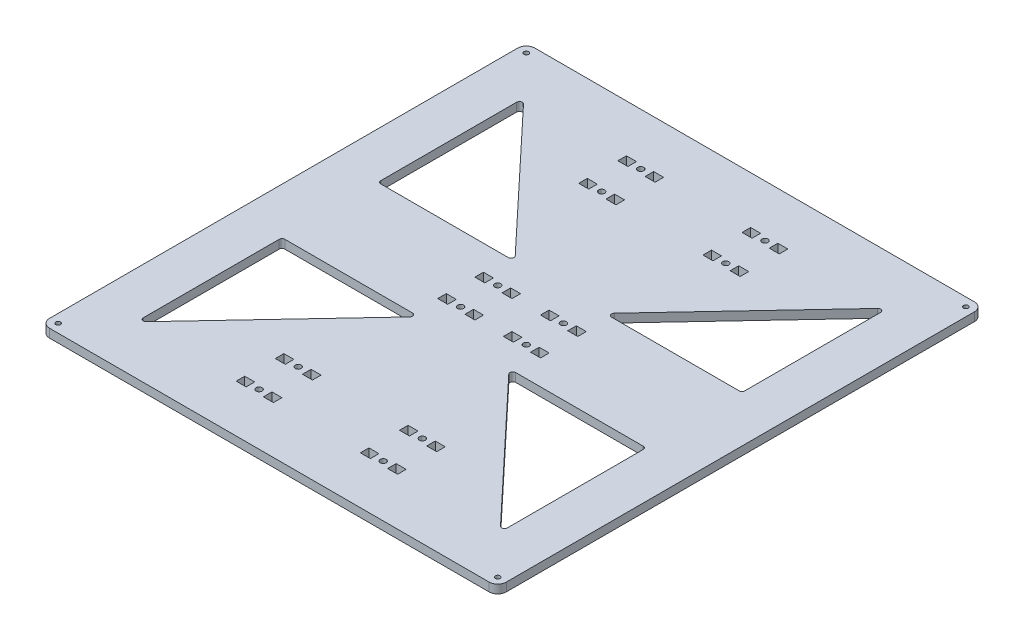
from build123d import *

# Parameters (mm, degrees)
SKETCH_1_R            = 1.65
EXTRUDE_1_DEPTH       = 6
SKETCH_3_R            = 2.1
SKETCH_3_W            = 7
SKETCH_3_H            = 6
CUT_EXTRUDE_1_DEPTH   = 7
SKETCH_31_R           = 2.1
SKETCH_31_W           = 7
SKETCH_31_H           = 6
CUT_EXTRUDE_11_DEPTH  = 7
SKETCH_32_R           = 2.1
SKETCH_32_W           = 7
SKETCH_32_H           = 6
CUT_EXTRUDE_12_DEPTH  = 7
SKETCH_33_R           = 2.1
SKETCH_33_W           = 7
SKETCH_33_H           = 6
CUT_EXTRUDE_13_DEPTH  = 7
SKETCH_34_R           = 2.1
SKETCH_34_W           = 7
SKETCH_34_H           = 6
CUT_EXTRUDE_14_DEPTH  = 7
SKETCH_35_R           = 2.1
SKETCH_35_W           = 7
SKETCH_35_H           = 6
CUT_EXTRUDE_15_DEPTH  = 7
SKETCH_37_R           = 2.1
SKETCH_37_W           = 7
SKETCH_37_H           = 6
CUT_EXTRUDE_17_DEPTH  = 7
SKETCH_38_R           = 2.1
SKETCH_38_W           = 7
SKETCH_38_H           = 6
CUT_EXTRUDE_18_DEPTH  = 7
SKETCH_39_R           = 2.1
SKETCH_39_W           = 7
SKETCH_39_H           = 6
CUT_EXTRUDE_19_DEPTH  = 7
SKETCH_310_R          = 2.1
SKETCH_310_W          = 7
SKETCH_310_H          = 6
CUT_EXTRUDE_110_DEPTH = 7
SKETCH_311_R          = 2.1
SKETCH_311_W          = 7
SKETCH_311_H          = 6
CUT_EXTRUDE_111_DEPTH = 7
SKETCH_312_R          = 2.1
SKETCH_312_W          = 7
SKETCH_312_H          = 6
CUT_EXTRUDE_112_DEPTH = 7
CUT_EXTRUDE_113_DEPTH = 7


with BuildPart() as part:
    # Эскиз1 → Бобышка-Вытянуть1 (new body)
    with BuildSketch(Plane(origin=(0, 0, 0), x_dir=(1, 0, 0), z_dir=(0, 1, 0))):
        with BuildLine():
            Line((-154, -156), (154, -156))
            ThreePointArc((154, -156), (158.242640687, -154.242640687), (160, -150))
            Line((160, -150), (160, 178))
            ThreePointArc((160, 178), (158.242640687, 182.242640687), (154, 184))
            Line((154, 184), (-154, 184))
            ThreePointArc((-154, 184), (-158.242640687, 182.242640687), (-160, 178))
            Line((-160, 178), (-160, -150))
            ThreePointArc((-160, -150), (-158.242640687, -154.242640687), (-154, -156))
        make_face()
        with Locations((-154, 178)):
            Circle(SKETCH_1_R, mode=Mode.SUBTRACT)
        with Locations((154, 178)):
            Circle(SKETCH_1_R, mode=Mode.SUBTRACT)
        with Locations((-154, -150)):
            Circle(SKETCH_1_R, mode=Mode.SUBTRACT)
        with Locations((154, -150)):
            Circle(SKETCH_1_R, mode=Mode.SUBTRACT)
    extrude(amount=EXTRUDE_1_DEPTH)

    # Эскиз3 → Вырез-Вытянуть1 (cut, through all)
    with BuildSketch(Plane(origin=(-23, 6, 20), x_dir=(1, 0, 0), z_dir=(0, 1, 0))):
        with Locations((0, 47)):
            Circle(SKETCH_3_R)
        with Locations((9.531849908, 47)):
            Rectangle(SKETCH_3_W, SKETCH_3_H)
        with Locations((-9.531849908, 47)):
            Rectangle(SKETCH_3_W, SKETCH_3_H)
    extrude(amount=-CUT_EXTRUDE_1_DEPTH, mode=Mode.SUBTRACT)

    # Эскиз31 → Вырез-Вытянуть11 (cut, through all)
    with BuildSketch(Plane(origin=(-23, 6, -48), x_dir=(-1, 0, 0), z_dir=(0, 1, 0))):
        with Locations((0, 47)):
            Circle(SKETCH_31_R)
        with Locations((9.531849908, 47)):
            Rectangle(SKETCH_31_W, SKETCH_31_H)
        with Locations((-9.531849908, 47)):
            Rectangle(SKETCH_31_W, SKETCH_31_H)
    extrude(amount=-CUT_EXTRUDE_11_DEPTH, mode=Mode.SUBTRACT)

    # Эскиз32 → Вырез-Вытянуть12 (cut, through all)
    with BuildSketch(Plane(origin=(23, 6, 20), x_dir=(1, 0, 0), z_dir=(0, 1, 0))):
        with Locations((0, 47)):
            Circle(SKETCH_32_R)
        with Locations((9.531849908, 47)):
            Rectangle(SKETCH_32_W, SKETCH_32_H)
        with Locations((-9.531849908, 47)):
            Rectangle(SKETCH_32_W, SKETCH_32_H)
    extrude(amount=-CUT_EXTRUDE_12_DEPTH, mode=Mode.SUBTRACT)

    # Эскиз33 → Вырез-Вытянуть13 (cut, through all)
    with BuildSketch(Plane(origin=(23, 6, -48), x_dir=(-1, 0, 0), z_dir=(0, 1, 0))):
        with Locations((0, 47)):
            Circle(SKETCH_33_R)
        with Locations((9.531849908, 47)):
            Rectangle(SKETCH_33_W, SKETCH_33_H)
        with Locations((-9.531849908, 47)):
            Rectangle(SKETCH_33_W, SKETCH_33_H)
    extrude(amount=-CUT_EXTRUDE_13_DEPTH, mode=Mode.SUBTRACT)

    # Эскиз34 → Вырез-Вытянуть14 (cut, through all)
    with BuildSketch(Plane(origin=(43.5, 6, 72.7), x_dir=(-1, 0, 0), z_dir=(0, 1, 0))):
        with Locations((0, 47)):
            Circle(SKETCH_34_R)
        with Locations((9.531849908, 47)):
            Rectangle(SKETCH_34_W, SKETCH_34_H)
        with Locations((-9.531849908, 47)):
            Rectangle(SKETCH_34_W, SKETCH_34_H)
    extrude(amount=-CUT_EXTRUDE_14_DEPTH, mode=Mode.SUBTRACT)

    # Эскиз35 → Вырез-Вытянуть15 (cut, through all)
    with BuildSketch(Plane(origin=(43.5, 6, 139.3), x_dir=(1, 0, 0), z_dir=(0, 1, 0))):
        with Locations((0, 47)):
            Circle(SKETCH_35_R)
        with Locations((9.531849908, 47)):
            Rectangle(SKETCH_35_W, SKETCH_35_H)
        with Locations((-9.531849908, 47)):
            Rectangle(SKETCH_35_W, SKETCH_35_H)
    extrude(amount=-CUT_EXTRUDE_15_DEPTH, mode=Mode.SUBTRACT)

    # Эскиз37 → Вырез-Вытянуть17 (cut, through all)
    with BuildSketch(Plane(origin=(-43.5, 6, 139.3), x_dir=(1, 0, 0), z_dir=(0, 1, 0))):
        with Locations((0, 47)):
            Circle(SKETCH_37_R)
        with Locations((9.531849908, 47)):
            Rectangle(SKETCH_37_W, SKETCH_37_H)
        with Locations((-9.531849908, 47)):
            Rectangle(SKETCH_37_W, SKETCH_37_H)
    extrude(amount=-CUT_EXTRUDE_17_DEPTH, mode=Mode.SUBTRACT)

    # Эскиз38 → Вырез-Вытянуть18 (cut, through all)
    with BuildSketch(Plane(origin=(-43.5, 6, 72.7), x_dir=(-1, 0, 0), z_dir=(0, 1, 0))):
        with Locations((0, 47)):
            Circle(SKETCH_38_R)
        with Locations((9.531849908, 47)):
            Rectangle(SKETCH_38_W, SKETCH_38_H)
        with Locations((-9.531849908, 47)):
            Rectangle(SKETCH_38_W, SKETCH_38_H)
    extrude(amount=-CUT_EXTRUDE_18_DEPTH, mode=Mode.SUBTRACT)

    # Эскиз39 → Вырез-Вытянуть19 (cut, through all)
    with BuildSketch(Plane(origin=(-43.5, 6, -100.7), x_dir=(1, 0, 0), z_dir=(0, 1, 0))):
        with Locations((0, 47)):
            Circle(SKETCH_39_R)
        with Locations((9.531849908, 47)):
            Rectangle(SKETCH_39_W, SKETCH_39_H)
        with Locations((-9.531849908, 47)):
            Rectangle(SKETCH_39_W, SKETCH_39_H)
    extrude(amount=-CUT_EXTRUDE_19_DEPTH, mode=Mode.SUBTRACT)

    # Эскиз310 → Вырез-Вытянуть110 (cut, through all)
    with BuildSketch(Plane(origin=(43.5, 6, -100.7), x_dir=(1, 0, 0), z_dir=(0, 1, 0))):
        with Locations((0, 47)):
            Circle(SKETCH_310_R)
        with Locations((9.531849908, 47)):
            Rectangle(SKETCH_310_W, SKETCH_310_H)
        with Locations((-9.531849908, 47)):
            Rectangle(SKETCH_310_W, SKETCH_310_H)
    extrude(amount=-CUT_EXTRUDE_110_DEPTH, mode=Mode.SUBTRACT)

    # Эскиз311 → Вырез-Вытянуть111 (cut, through all)
    with BuildSketch(Plane(origin=(-43.5, 6, -167.3), x_dir=(-1, 0, 0), z_dir=(0, 1, 0))):
        with Locations((0, 47)):
            Circle(SKETCH_311_R)
        with Locations((9.531849908, 47)):
            Rectangle(SKETCH_311_W, SKETCH_311_H)
        with Locations((-9.531849908, 47)):
            Rectangle(SKETCH_311_W, SKETCH_311_H)
    extrude(amount=-CUT_EXTRUDE_111_DEPTH, mode=Mode.SUBTRACT)

    # Эскиз312 → Вырез-Вытянуть112 (cut, through all)
    with BuildSketch(Plane(origin=(43.5, 6, -167.3), x_dir=(-1, 0, 0), z_dir=(0, 1, 0))):
        with Locations((0, 47)):
            Circle(SKETCH_312_R)
        with Locations((9.531849908, 47)):
            Rectangle(SKETCH_312_W, SKETCH_312_H)
        with Locations((-9.531849908, 47)):
            Rectangle(SKETCH_312_W, SKETCH_312_H)
    extrude(amount=-CUT_EXTRUDE_112_DEPTH, mode=Mode.SUBTRACT)

    # Эскиз313 → Вырез-Вытянуть113 (cut, through all)
    with BuildSketch(Plane(origin=(0, 6, 0), x_dir=(1, 0, 0), z_dir=(0, 1, 0))):
        with BuildLine():
            Line((-127.516979969, 144.745730497), (-127.516979969, 49.590777688))
            ThreePointArc((-127.516979969, 49.590777688), (-126.931193532, 48.176564126), (-125.516979969, 47.590777688))
            Line((-125.516979969, 47.590777688), (-36.16415843, 47.590777688))
            ThreePointArc((-36.16415843, 47.590777688), (-34.328657222, 48.796463318), (-34.706193444, 50.959842369))
            Line((-34.706193444, 50.959842369), (-124.059014984, 146.114795178))
            ThreePointArc((-124.059014984, 146.114795178), (-126.253210242, 146.605290925), (-127.516979969, 144.745730497))
        make_face()
        with BuildLine():
            Line((34.706193444, 50.959842369), (124.059014984, 146.114795178))
            ThreePointArc((124.059014984, 146.114795178), (126.253210242, 146.605290925), (127.516979969, 144.745730497))
            Line((127.516979969, 144.745730497), (127.516979969, 49.590777688))
            ThreePointArc((127.516979969, 49.590777688), (126.931193532, 48.176564126), (125.516979969, 47.590777688))
            Line((125.516979969, 47.590777688), (36.16415843, 47.590777688))
            ThreePointArc((36.16415843, 47.590777688), (34.328657222, 48.796463318), (34.706193444, 50.959842369))
        make_face()
        with BuildLine():
            Line((127.516979969, -116.745730497), (127.516979969, -21.590777688))
            ThreePointArc((127.516979969, -21.590777688), (126.931193532, -20.176564126), (125.516979969, -19.590777688))
            Line((125.516979969, -19.590777688), (36.16415843, -19.590777688))
            ThreePointArc((36.16415843, -19.590777688), (34.328657222, -20.796463318), (34.706193444, -22.959842369))
            Line((34.706193444, -22.959842369), (124.059014984, -118.114795178))
            ThreePointArc((124.059014984, -118.114795178), (126.253210242, -118.605290925), (127.516979969, -116.745730497))
        make_face()
        with BuildLine():
            Line((-34.706193444, -22.959842369), (-124.059014984, -118.114795178))
            ThreePointArc((-124.059014984, -118.114795178), (-126.253210242, -118.605290925), (-127.516979969, -116.745730497))
            Line((-127.516979969, -116.745730497), (-127.516979969, -21.590777688))
            ThreePointArc((-127.516979969, -21.590777688), (-126.931193532, -20.176564126), (-125.516979969, -19.590777688))
            Line((-125.516979969, -19.590777688), (-36.16415843, -19.590777688))
            ThreePointArc((-36.16415843, -19.590777688), (-34.328657222, -20.796463318), (-34.706193444, -22.959842369))
        make_face()
    extrude(amount=-CUT_EXTRUDE_113_DEPTH, mode=Mode.SUBTRACT)


solid = part.part
